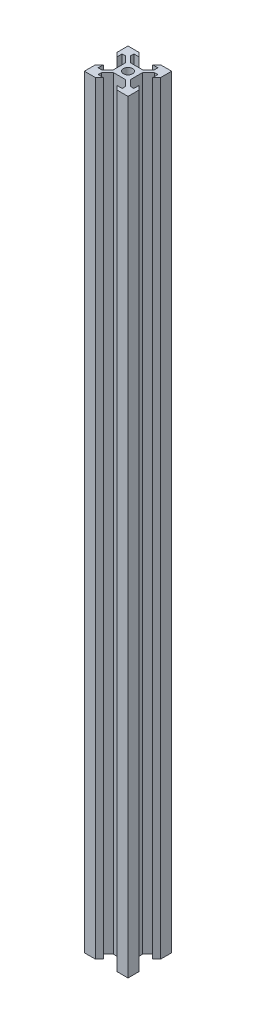
from build123d import *

# Parameters (mm, degrees)
SKETCH_1_R      = 2.1
EXTRUDE_1_DEPTH = 350


with BuildPart() as part:
    # 草图1 → 凸台-拉伸1 (new body)
    with BuildSketch(Plane(origin=(0, 0, 0), x_dir=(1, 0, 0), z_dir=(0, 1, 0))):
        Polygon((-10, 10), (-4.9, 10), (-3.1, 8.2), (-5.5, 8.2), (-5.5, 6.560660172), (-2.839339828, 3.9), (0, 3.9), (2.839339828, 3.9), (5.5, 6.560660172), (5.5, 8.2), (3.1, 8.2), (4.9, 10), (10, 10), (10, 4.9), (8.2, 3.1), (8.2, 5.5), (6.560660172, 5.5), (3.9, 2.839339828), (3.9, -2.839339828), (6.560660172, -5.5), (8.2, -5.5), (8.2, -3.1), (10, -4.9), (10, -10), (4.9, -10), (3.1, -8.2), (5.5, -8.2), (5.5, -6.560660172), (2.839339828, -3.9), (0, -3.9), (-2.839339828, -3.9), (-5.5, -6.560660172), (-5.5, -8.2), (-3.1, -8.2), (-4.9, -10), (-10, -10), (-10, -4.9), (-8.2, -3.1), (-8.2, -5.5), (-6.560660172, -5.5), (-3.9, -2.839339828), (-3.9, 2.839339828), (-6.560660172, 5.5), (-8.2, 5.5), (-8.2, 3.1), (-10, 4.9), align=None)
        Circle(SKETCH_1_R, mode=Mode.SUBTRACT)
    extrude(amount=EXTRUDE_1_DEPTH)


solid = part.part
